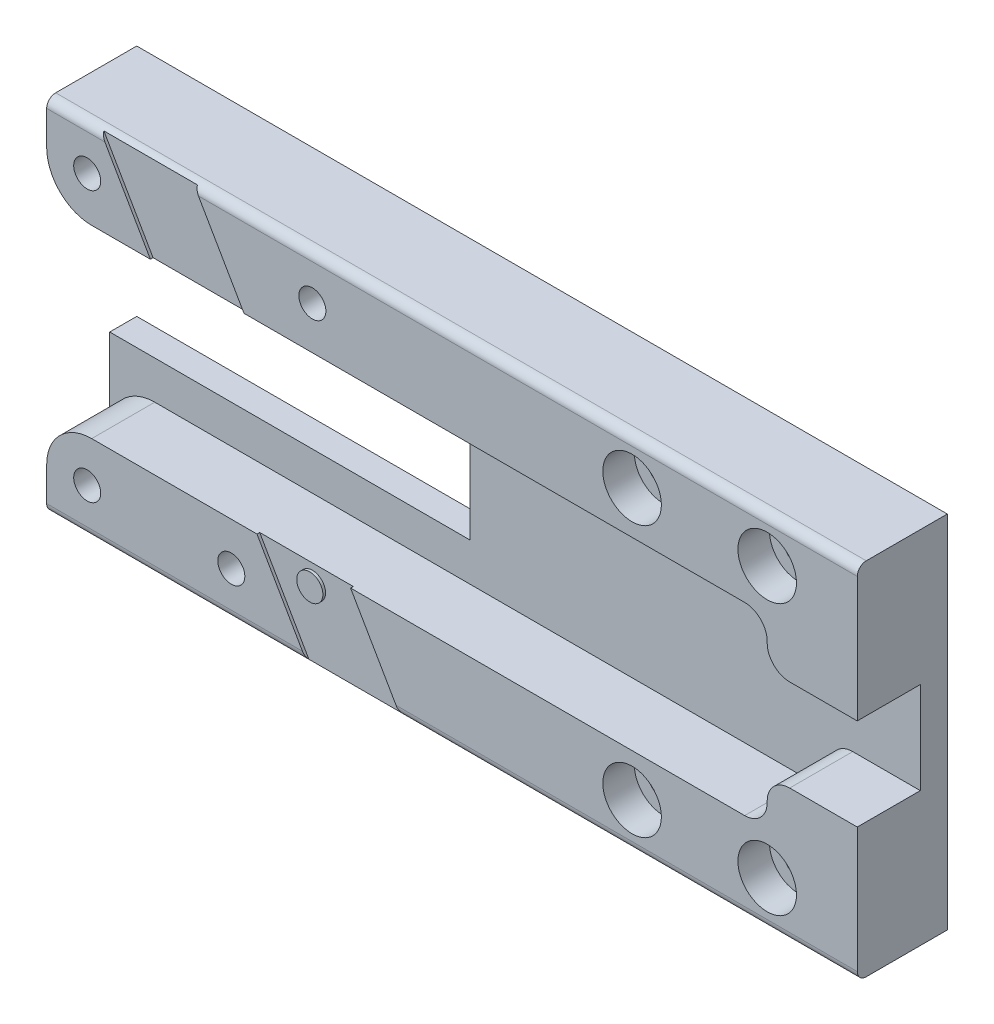
from build123d import *

# Parameters (mm, degrees)
SKETCH_1_W           = 255
SKETCH_1_H           = 80
EXTRUDE_1_DEPTH      = 5
SKETCH_2_R           = 5
CUT_EXTRUDE_1_DEPTH  = 5
SKETCH_3_R           = 4
CUT_EXTRUDE_2_DEPTH  = 10
SKETCH_4_W           = 50
SKETCH_4_H           = 20
EXTRUDE_2_DEPTH      = 10
SKETCH_5_R           = 15
CUT_EXTRUDE_3_DEPTH  = 10
SKETCH_6_R           = 7
EXTRUDE_3_DEPTH      = 15
HOLE_WIZARD_M6_1_D   = 5
CUT_EXTRUDE_4_DEPTH  = 7
HOLE_WIZARD_M4_1_D   = 3.3
FILLET_1_R           = 10
SKETCH_13_R          = 6.969385005
EXTRUDE_5_DEPTH      = 5
SKETCH_14_W          = 5
SKETCH_14_H          = 75
EXTRUDE_6_DEPTH      = 80
SKETCH_15_W          = 20
SKETCH_15_H          = 5
EXTRUDE_7_DEPTH      = 80
EXTRUDE_8_DEPTH      = 5
SKETCH_17_R          = 3
CUT_EXTRUDE_5_DEPTH  = 5
FILLET_2_R           = 1
SKETCH_18_W          = 309.613912266
SKETCH_18_H          = 134.290371586
CUT_EXTRUDE_6_DEPTH  = 81
SKETCH_19_R          = 17
CUT_EXTRUDE_7_DEPTH  = 11
SKETCH_20_W          = 10
SKETCH_20_H          = 10
EXTRUDE_9_DEPTH      = 50
SKETCH_21_R          = 1.75
CUT_EXTRUDE_8_DEPTH  = 11
SKETCH_22_R          = 3.25
CUT_EXTRUDE_9_DEPTH  = 3.5
FILLET_4_R           = 1
EXTRUDE_10_DEPTH     = 40
SKETCH_24_W          = 160
SKETCH_24_H          = 20.5
CUT_EXTRUDE_10_DEPTH = 7
SKETCH_25_W          = 80
SKETCH_25_H          = 12
CUT_EXTRUDE_11_DEPTH = 4
FILLET_5_R           = 5
CUT_EXTRUDE_12_DEPTH = 0.3
SKETCH_27_R          = 1.45
EXTRUDE_11_DEPTH     = 0.3
F_3_0MM_1_D          = 3
FILLET_6_R           = 2.5


with BuildPart() as part:
    # 草图1 → 凸台-拉伸1 (new body)
    with BuildSketch(Plane.XY):
        Rectangle(SKETCH_1_W, SKETCH_1_H)
    extrude(amount=EXTRUDE_1_DEPTH)

    # 草图2 → 切除-拉伸1 (cut)
    with BuildSketch(Plane.XY.offset(5)):
        with Locations((-107.5, 0)):
            Circle(SKETCH_2_R)
    extrude(amount=-CUT_EXTRUDE_1_DEPTH, mode=Mode.SUBTRACT)

    # 草图3 → 切除-拉伸2 (cut)
    with BuildSketch(Plane.XY.offset(5)):
        with Locations((-45, 0)):
            Circle(SKETCH_3_R)
    extrude(amount=-CUT_EXTRUDE_2_DEPTH, mode=Mode.SUBTRACT)

    # 草图4 → 凸台-拉伸2 (add)
    with BuildSketch(Plane.XY.offset(5)):
        with Locations((-22.5, 0)):
            Rectangle(SKETCH_4_W, SKETCH_4_H)
    extrude(amount=EXTRUDE_2_DEPTH)

    # 草图5 → 切除-拉伸3 (cut)
    with BuildSketch(Plane.XY.offset(5)):
        with Locations((70, 0)):
            Circle(SKETCH_5_R)
    extrude(amount=-CUT_EXTRUDE_3_DEPTH, mode=Mode.SUBTRACT)

    # 草图6 → 凸台-拉伸3 (add)
    with BuildSketch(Plane(origin=(0, 0, 0), x_dir=(-1, 0, 0), z_dir=(0, 0, -1))):
        with Locations((107.5, 0)):
            Circle(SKETCH_6_R)
    extrude(amount=-EXTRUDE_3_DEPTH)

    # M6 螺纹孔1 (through all)
    with Locations(Plane.XY.offset(15)):
        with Locations((-107.5, 0)):
            Hole(HOLE_WIZARD_M6_1_D / 2)

    # 草图10 → 切除-拉伸4 (cut)
    with BuildSketch(Plane.XY.offset(15)):
        with BuildLine():
            Line((-47.5, 5.1), (2.5, 5.1))
            ThreePointArc((2.5, 5.1), (7.6, 0), (2.5, -5.1))
            Line((2.5, -5.1), (-47.5, -5.1))
            ThreePointArc((-47.5, -5.1), (-52.6, 0), (-47.5, 5.1))
        make_face()
    extrude(amount=-CUT_EXTRUDE_4_DEPTH, mode=Mode.SUBTRACT)

    # M4 螺纹孔1 (through all)
    with Locations(Plane(origin=(0, 0, 0), x_dir=(-1, 0, 0), z_dir=(0, 0, -1))):
        with Locations((-39.75, -26.5), (-39.75, -1.5), (-109.94007449, -26.5), (-100.25, -1.5)):
            Hole(HOLE_WIZARD_M4_1_D / 2)

    # 圆角1
    fillet_1_edges = [part.edges().sort_by_distance(p)[0] for p in [
        (-127.5, 40, 2.5),
        (-127.5, -40, 2.5),
    ]]
    fillet(fillet_1_edges, radius=FILLET_1_R)

    # 草图13 → 凸台-拉伸5 (add)
    with BuildSketch(Plane.XY.offset(5)):
        with Locations((-45, 0)):
            Circle(SKETCH_13_R)
    extrude(amount=-EXTRUDE_5_DEPTH)

    # 草图14 → 凸台-拉伸6 (add)
    with BuildSketch(Plane.XZ.offset(40)):
        with Locations((125, -37.5)):
            Rectangle(SKETCH_14_W, SKETCH_14_H)
    extrude(amount=-EXTRUDE_6_DEPTH)

    # 草图15 → 凸台-拉伸7 (add)
    with BuildSketch(Plane.XZ.offset(40)):
        with Locations((112.5, -72.5)):
            Rectangle(SKETCH_15_W, SKETCH_15_H)
    extrude(amount=-EXTRUDE_7_DEPTH)

    # 草图16 → 凸台-拉伸8 (add)
    with BuildSketch(Plane.XZ.offset(40)):
        Polygon((-32.5, 5), (-32.5, 0), (102.5, -75), (127.5, -75), (127.5, 5), align=None)
    extrude_8 = extrude(amount=-EXTRUDE_8_DEPTH)

    # 镜向1: 凸台-拉伸8 across plane
    add(extrude_8.mirror(Plane.ZX))

    # 草图17 → 切除-拉伸5 (cut)
    with BuildSketch(Plane(origin=(0, 0, -75), x_dir=(-1, 0, 0), z_dir=(0, 0, -1))):
        with Locations((-114.5, -15)):
            Circle(SKETCH_17_R)
        with Locations((-114.5, 15)):
            Circle(SKETCH_17_R)
    extrude(amount=-CUT_EXTRUDE_5_DEPTH, mode=Mode.SUBTRACT)

    # 圆角2
    fillet_2_edges = [part.edges().sort_by_distance(p)[0] for p in [
        (-75, -40, 0),
        (5, -40, 5),
        (-127.5, 0, 0),
        (-124.571067812, 37.071067812, 0),
        (-124.571067812, -37.071067812, 0),
        (-127.5, 0, 5),
        (-124.571067812, 37.071067812, 5),
        (-124.571067812, -37.071067812, 5),
        (127.5, 0, 5),
        (127.5, 0, -75),
        (115, -40, -75),
        (115, 40, -75),
        (35, -40, -37.5),
        (35, -35, -37.5),
        (5, 40, 5),
        (-75, 40, 0),
        (35, 40, -37.5),
        (35, 35, -37.5),
        (127.5, 40, -35),
        (127.5, -40, -35),
    ]]
    fillet(fillet_2_edges, radius=FILLET_2_R)

    # 草图18 → 切除-拉伸6 (cut, through all)
    with BuildSketch(Plane.XY.offset(5)):
        Rectangle(SKETCH_18_W, SKETCH_18_H)
    extrude(amount=-CUT_EXTRUDE_6_DEPTH, mode=Mode.SUBTRACT)

    # 草图19 → 切除-拉伸7 (cut, through all)
    with BuildSketch(Plane.XY.offset(15)):
        with Locations((-107.5, 0)):
            Circle(SKETCH_19_R)
    extrude(amount=-CUT_EXTRUDE_7_DEPTH, mode=Mode.SUBTRACT)

    # 草图20 → 凸台-拉伸9 (add)
    with BuildSketch(Plane(origin=(2.5, 0, 0), x_dir=(0, 0, -1), z_dir=(1, 0, 0))):
        with Locations((-10, 15)):
            Rectangle(SKETCH_20_W, SKETCH_20_H)
    extrude_9 = extrude(amount=-EXTRUDE_9_DEPTH)

    # 镜向2: 凸台-拉伸9 across plane
    add(extrude_9.mirror(Plane.ZX))

    # 草图21 → 切除-拉伸8 (cut, through all)
    with BuildSketch(Plane.XY.offset(15)):
        with Locations((-22.5, 15)):
            Circle(SKETCH_21_R)
        with Locations((-7.5, 15)):
            Circle(SKETCH_21_R)
        with Locations((-7.5, -15)):
            Circle(SKETCH_21_R)
        with Locations((-22.5, -15)):
            Circle(SKETCH_21_R)
    extrude(amount=-CUT_EXTRUDE_8_DEPTH, mode=Mode.SUBTRACT)

    # 草图22 → 切除-拉伸9 (cut)
    with BuildSketch(Plane.XY.offset(15)):
        with Locations((-22.5, 15)):
            Circle(SKETCH_22_R)
        with Locations((-7.5, 15)):
            Circle(SKETCH_22_R)
        with Locations((-7.5, -15)):
            Circle(SKETCH_22_R)
        with Locations((-22.5, -15)):
            Circle(SKETCH_22_R)
    extrude(amount=-CUT_EXTRUDE_9_DEPTH, mode=Mode.SUBTRACT)

    # 圆角4
    fillet_4_edges = [part.edges().sort_by_distance(p)[0] for p in [
        (-22.5, 20, 15),
        (-22.5, -20, 15),
    ]]
    fillet(fillet_4_edges, radius=FILLET_4_R)

    # 草图23 → 凸台-拉伸10 (add)
    with BuildSketch(Plane.ZY.offset(47.5)):
        with BuildLine():
            Line((5, -20), (14, -20))
            ThreePointArc((14, -20), (14.707106781, -19.707106781), (15, -19))
            Line((15, -19), (15, -5.1))
            Line((15, -5.1), (8, -5.1))
            Line((8, -5.1), (8, 5.1))
            Line((8, 5.1), (15, 5.1))
            Line((15, 5.1), (15, 19))
            ThreePointArc((15, 19), (14.707106781, 19.707106781), (14, 20))
            Line((14, 20), (5, 20))
            Line((5, 20), (5, -20))
        make_face()
    extrude(amount=EXTRUDE_10_DEPTH)

    # 草图24 → 切除-拉伸10 (cut)
    with BuildSketch(Plane.XY.offset(15)):
        with Locations((-87.5, 0)):
            Rectangle(SKETCH_24_W, SKETCH_24_H)
    extrude(amount=-CUT_EXTRUDE_10_DEPTH, mode=Mode.SUBTRACT)

    # 草图25 → 切除-拉伸11 (cut, through all)
    with BuildSketch(Plane.XY.offset(8)):
        with Locations((-87.5, 0)):
            Rectangle(SKETCH_25_W, SKETCH_25_H)
    extrude(amount=-CUT_EXTRUDE_11_DEPTH, mode=Mode.SUBTRACT)

    # 圆角5
    fillet_5_edges = [part.edges().sort_by_distance(p)[0] for p in [
        (-87.5, 10.25, 11.5),
        (-87.5, -10.25, 11.5),
    ]]
    fillet(fillet_5_edges, radius=FILLET_5_R)

    # 草图26 → 切除-拉伸12 (cut)
    with BuildSketch(Plane.XY.offset(15)):
        Polygon((-58.521459286, -20), (-81.615470054, 20), (-71.223165208, 20), (-48.129154441, -20), align=None)
    extrude(amount=-CUT_EXTRUDE_12_DEPTH, mode=Mode.SUBTRACT)

    # 草图27 → 凸台-拉伸11 (add)
    with BuildSketch(Plane.XY.offset(14.7)):
        with Locations((-58.285898385, -12.408003449)):
            Circle(SKETCH_27_R)
    extrude(amount=EXTRUDE_11_DEPTH)

    # Ø3.0mm 暗销孔1 (through all)
    with Locations(Plane.XY.offset(15)):
        with Locations((-83, 15), (-58, 15), (-67, -15), (-83, -15)):
            Hole(F_3_0MM_1_D / 2)

    # 圆角6
    fillet_6_edges = [part.edges().sort_by_distance(p)[0] for p in [
        (-7.5, -5.1, 11.5),
        (-7.5, 5.1, 11.5),
        (-7.5, 10.25, 11.5),
        (-7.5, -10.25, 11.5),
    ]]
    fillet(fillet_6_edges, radius=FILLET_6_R)


solid = part.part
